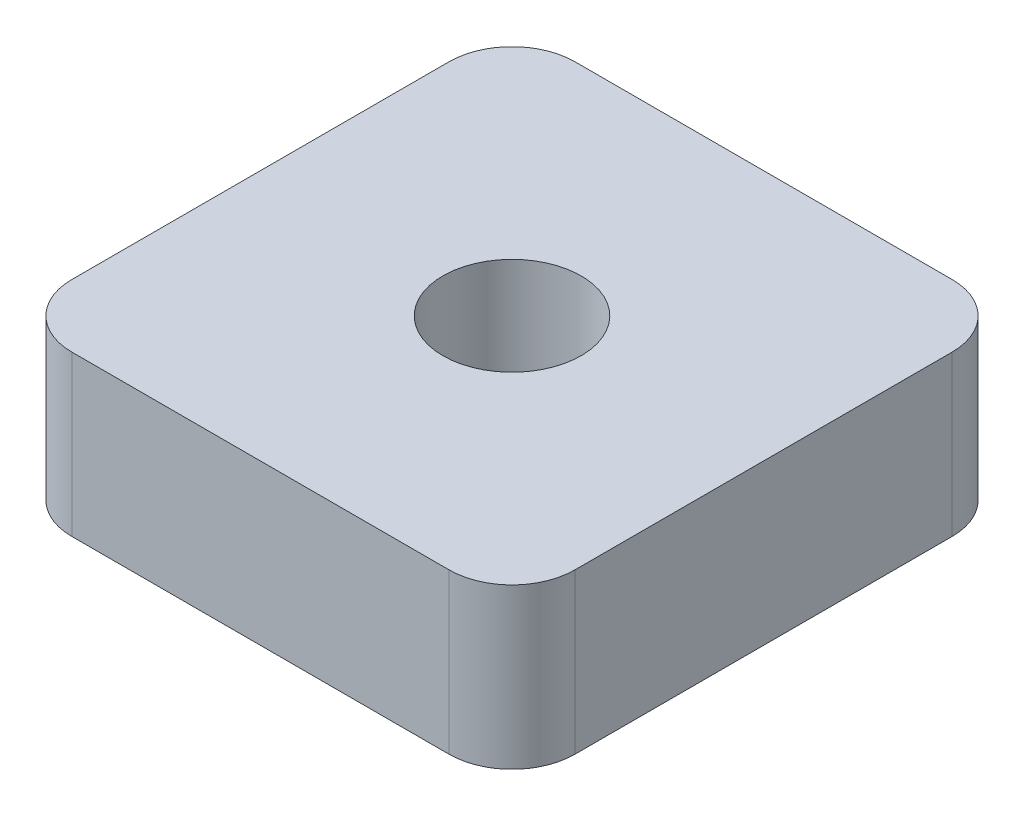
from build123d import *

# Parameters (mm, degrees)
SKETCH1_W            = 20
SKETCH1_H            = 20
BOSS_EXTRUDE1_DEPTH  = 6.35
M5_CLEARANCE_HOLE1_D = 5.5
FILLET1_R            = 2.5


with BuildPart() as part:
    # Sketch1 → Boss-Extrude1 (new body)
    with BuildSketch(Plane(origin=(0, 0, 0), x_dir=(1, 0, 0), z_dir=(0, 1, 0))):
        Rectangle(SKETCH1_W, SKETCH1_H)
    extrude(amount=BOSS_EXTRUDE1_DEPTH)

    # M5 Clearance Hole1 (through all)
    with Locations(Plane(origin=(0, 6.35, 0), x_dir=(1, 0, 0), z_dir=(0, 1, 0))):
        with Locations((0, 0)):
            Hole(M5_CLEARANCE_HOLE1_D / 2)

    # Fillet1
    fillet1_edges = [part.edges().sort_by_distance(p)[0] for p in [
        (10, 3.175, 10),
        (-10, 3.175, 10),
        (-10, 3.175, -10),
        (10, 3.175, -10),
    ]]
    fillet(fillet1_edges, radius=FILLET1_R)


solid = part.part
